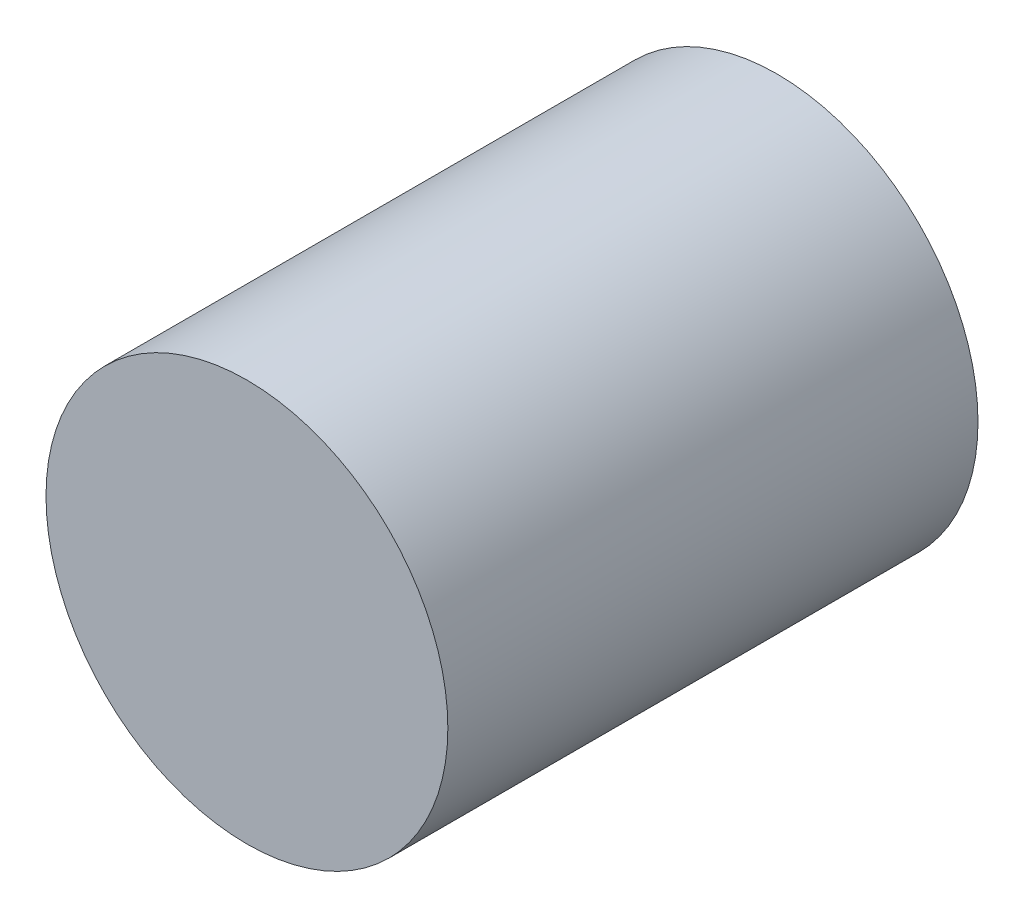
from build123d import *

# Parameters (mm, degrees)
SKETCH_2_R      = 15.160502364
EXTRUDE_2_DEPTH = 40


with BuildPart() as part:
    # 草图2 → 凸台-拉伸2 (new body)
    with BuildSketch(Plane.XY):
        with Locations((99.149873222, -15.087259813)):
            Circle(SKETCH_2_R)
    extrude(amount=-EXTRUDE_2_DEPTH)


solid = part.part
